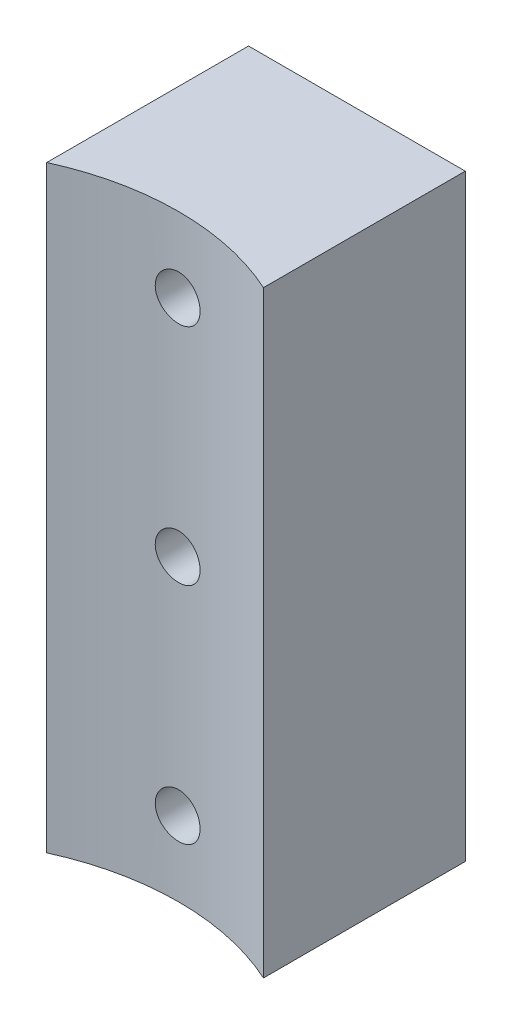
from build123d import *

# Parameters (mm, degrees)
BOSS_EXTRUDE1_DEPTH = 80
SKETCH2_R           = 3
CUT_EXTRUDE1_DEPTH  = 28


with BuildPart() as part:
    # Sketch1 → Boss-Extrude1 (new body)
    with BuildSketch(Plane(origin=(0, 0, 0), x_dir=(1, 0, 0), z_dir=(0, 1, 0))):
        with BuildLine():
            Line((-14.5, 13.5), (14.5, 13.5))
            Line((14.5, 13.5), (14.5, -13.5))
            ThreePointArc((14.5, -13.5), (0, -10.355140872), (-14.5, -13.5))
            Line((-14.5, -13.5), (-14.5, 13.5))
        make_face()
    extrude(amount=BOSS_EXTRUDE1_DEPTH)

    # Sketch2 → Cut-Extrude1 (cut, through all)
    with BuildSketch(Plane(origin=(0, 0, -13.5), x_dir=(-1, 0, 0), z_dir=(0, 0, -1))):
        with Locations((0, 70)):
            Circle(SKETCH2_R)
        with Locations((0, 40)):
            Circle(SKETCH2_R)
        with Locations((0, 10)):
            Circle(SKETCH2_R)
    extrude(amount=-CUT_EXTRUDE1_DEPTH, mode=Mode.SUBTRACT)


solid = part.part
